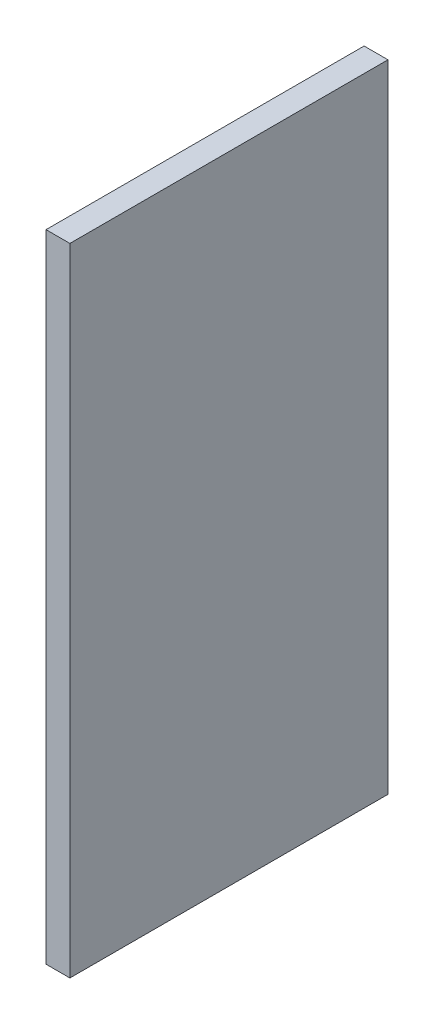
from build123d import *

# Parameters (mm, degrees)
ESQUISSE2_W        = 6
ESQUISSE2_H        = 160
BOSS_EXTRU_1_DEPTH = 80


with BuildPart() as part:
    # Esquisse2 → Boss.-Extru.1 (new body)
    with BuildSketch(Plane.XY):
        with Locations((3, 80)):
            Rectangle(ESQUISSE2_W, ESQUISSE2_H)
    extrude(amount=BOSS_EXTRU_1_DEPTH)


solid = part.part
